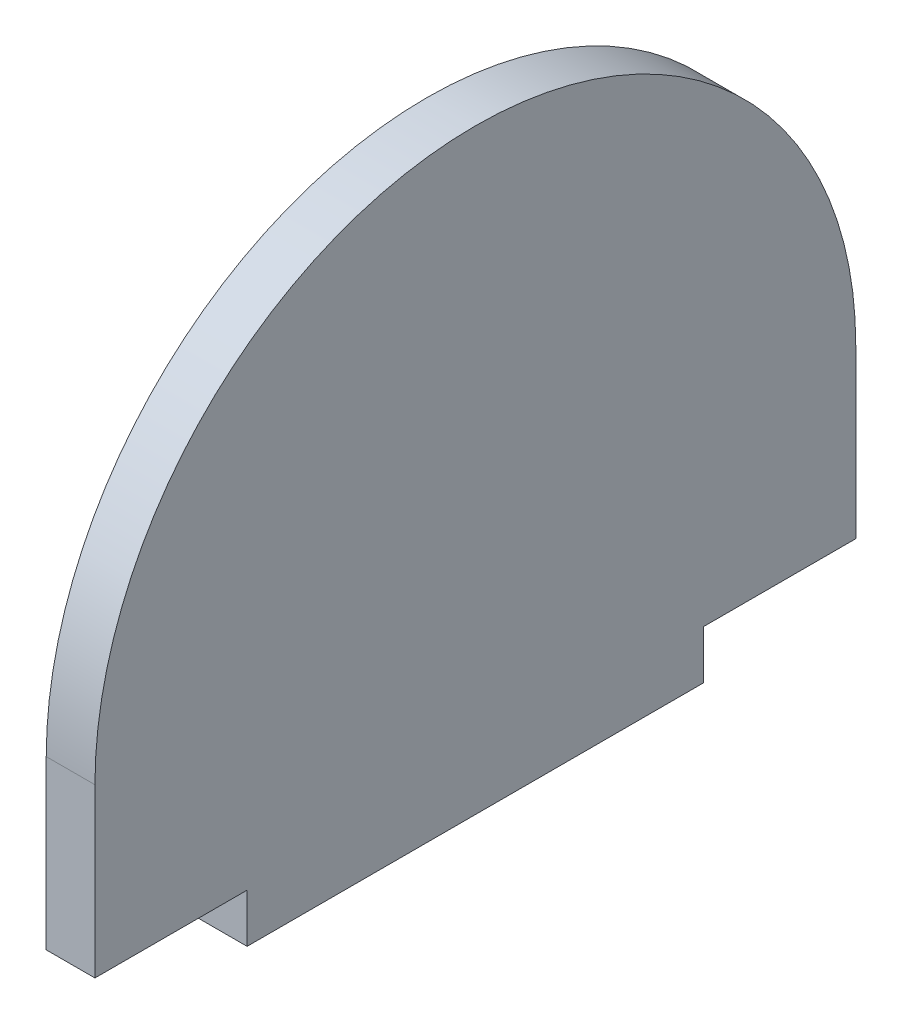
from build123d import *

# Parameters (mm, degrees)
BOSS_EXTRUDE1_DEPTH = 3.2


with BuildPart() as part:
    # Sketch1 → Boss-Extrude1 (new body)
    with BuildSketch(Plane(origin=(0, 0, 0), x_dir=(0, 0, -1), z_dir=(1, 0, 0))):
        with BuildLine():
            Line((20.841502971, -18.387853518), (30.841502971, -18.387853518))
            Line((30.841502971, -18.387853518), (30.841502971, -7.387853518))
            ThreePointArc((30.841502971, -7.387853518), (5.841502971, 17.612146482), (-19.158497029, -7.387853518))
            Line((-19.158497029, -7.387853518), (-19.158497029, -18.387853518))
            Line((-19.158497029, -18.387853518), (-9.158497029, -18.387853518))
            Line((-9.158497029, -18.387853518), (-9.158497029, -21.587853518))
            Line((-9.158497029, -21.587853518), (20.841502971, -21.587853518))
            Line((20.841502971, -21.587853518), (20.841502971, -18.387853518))
        make_face()
    extrude(amount=BOSS_EXTRUDE1_DEPTH)


solid = part.part
